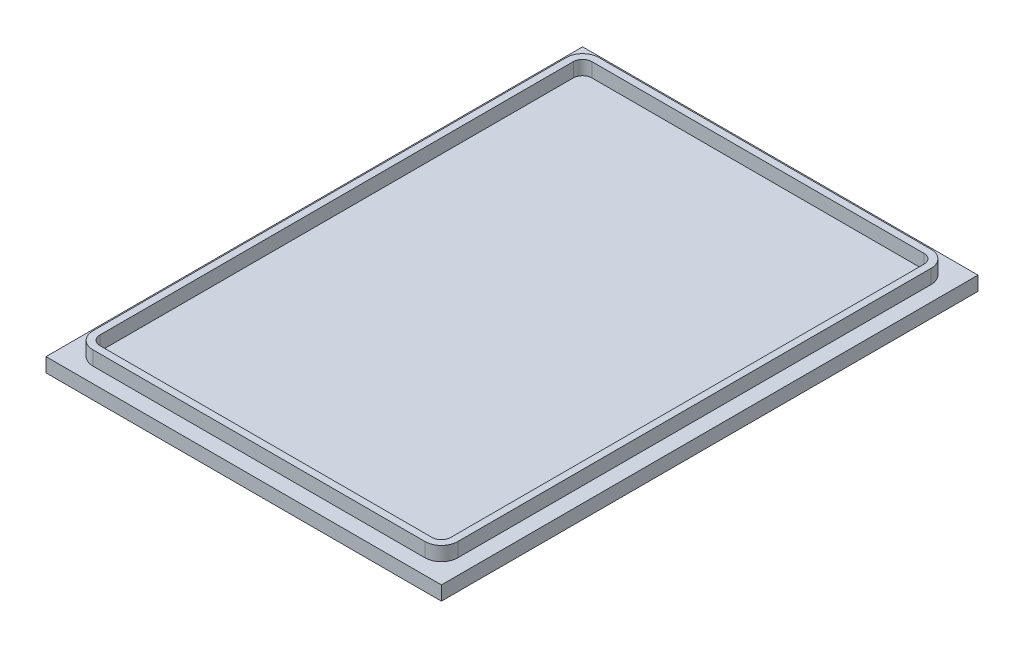
from build123d import *

# Parameters (mm, degrees)
SKETCH1_W           = 88.9
SKETCH1_H           = 120.65
BOSS_EXTRUDE1_DEPTH = 3.175
BOSS_EXTRUDE2_DEPTH = 3.175
CUT_EXTRUDE1_DEPTH  = 3.175


with BuildPart() as part:
    # Sketch1 → Boss-Extrude1 (new body)
    with BuildSketch(Plane(origin=(0, 0, 0), x_dir=(1, 0, 0), z_dir=(0, 1, 0))):
        Rectangle(SKETCH1_W, SKETCH1_H)
    extrude(amount=BOSS_EXTRUDE1_DEPTH)

    # Sketch2 → Boss-Extrude2 (add)
    with BuildSketch(Plane(origin=(0, 3.175, 0), x_dir=(1, 0, 0), z_dir=(0, 1, 0))):
        with BuildLine():
            Line((-37.338, 56.896), (37.338, 56.896))
            ThreePointArc((37.338, 56.896), (39.942274275, 55.817274275), (41.021, 53.213))
            Line((41.021, 53.213), (41.021, -53.213))
            ThreePointArc((41.021, -53.213), (39.942274275, -55.817274275), (37.338, -56.896))
            Line((37.338, -56.896), (-37.338, -56.896))
            ThreePointArc((-37.338, -56.896), (-39.942274275, -55.817274275), (-41.021, -53.213))
            Line((-41.021, -53.213), (-41.021, 53.213))
            ThreePointArc((-41.021, 53.213), (-39.942274275, 55.817274275), (-37.338, 56.896))
        make_face()
    extrude(amount=BOSS_EXTRUDE2_DEPTH)

    # Sketch3 → Cut-Extrude1 (cut)
    with BuildSketch(Plane(origin=(0, 6.35, 0), x_dir=(1, 0, 0), z_dir=(0, 1, 0))):
        with BuildLine():
            Line((-37.338, -55.3085), (37.338, -55.3085))
            ThreePointArc((37.338, -55.3085), (38.81974226, -54.69474226), (39.4335, -53.213))
            Line((39.4335, -53.213), (39.4335, 53.213))
            ThreePointArc((39.4335, 53.213), (38.81974226, 54.69474226), (37.338, 55.3085))
            Line((37.338, 55.3085), (-37.338, 55.3085))
            ThreePointArc((-37.338, 55.3085), (-38.81974226, 54.69474226), (-39.4335, 53.213))
            Line((-39.4335, 53.213), (-39.4335, -53.213))
            ThreePointArc((-39.4335, -53.213), (-38.81974226, -54.69474226), (-37.338, -55.3085))
        make_face()
    extrude(amount=-CUT_EXTRUDE1_DEPTH, mode=Mode.SUBTRACT)


solid = part.part
